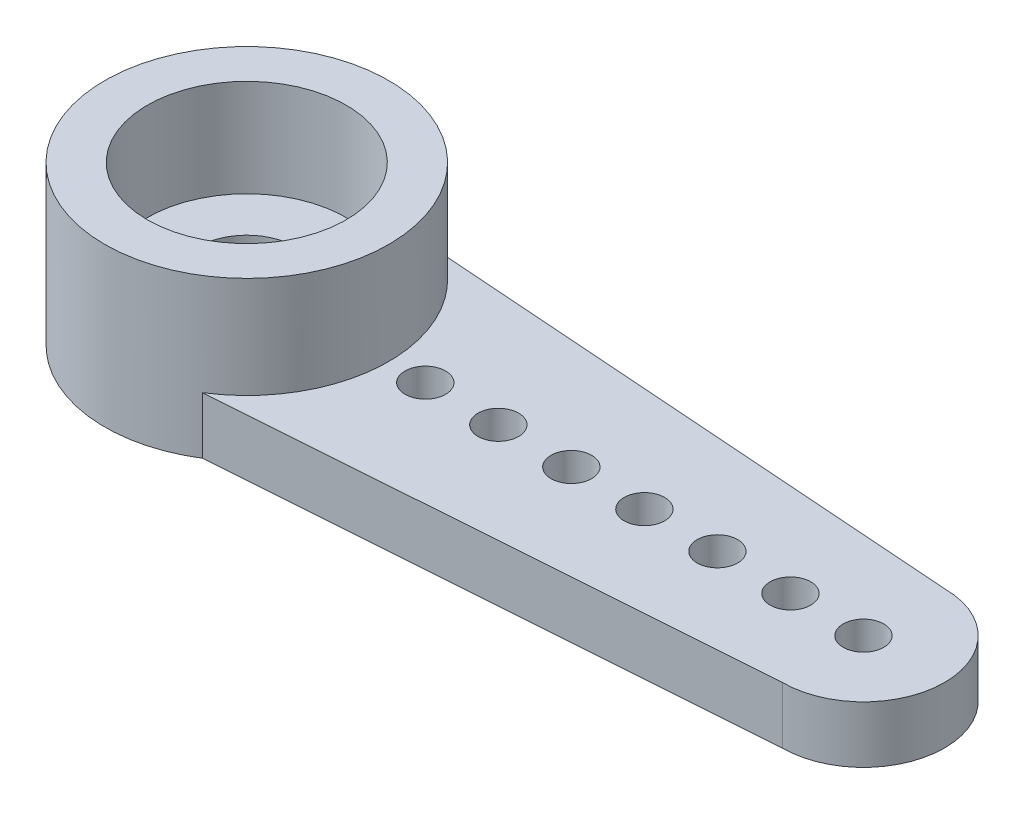
from build123d import *

# Parameters (mm, degrees)
SKETCH1_R           = 0.5
BOSS_EXTRUDE1_DEPTH = 1.4
SKETCH2_R           = 2.35
CUT_EXTRUDE1_DEPTH  = 1
SKETCH3_R           = 3.5
SKETCH3_R_2         = 2.45
BOSS_EXTRUDE2_DEPTH = 2.5
SKETCH4_R           = 1.2
CUT_EXTRUDE2_DEPTH  = 2.4
SKETCH5_R           = 2.45
SKETCH5_R_2         = 1.2
BOSS_EXTRUDE3_DEPTH = 0.1
SKETCH6_W           = 35.735260114
SKETCH6_H           = 17.672039004
CUT_EXTRUDE4_DEPTH  = 4.9
CUT_EXTRUDE5_DEPTH  = 4.9


with BuildPart() as part:
    # Sketch1 → Boss-Extrude1 (new body)
    with BuildSketch(Plane(origin=(0, 0, 0), x_dir=(1, 0, 0), z_dir=(0, 1, 0))):
        with BuildLine():
            Line((-15.2, 2), (-2, 2.95))
            Line((-2, 2.95), (-2, 6.35))
            ThreePointArc((-2, 6.35), (0, 8.35), (2, 6.35))
            Line((2, 6.35), (2, 3.5))
            Line((2, 3.5), (15.2, 2))
            ThreePointArc((15.2, 2), (17.2, 0), (15.2, -2))
            Line((15.2, -2), (2, -3.5))
            Line((2, -3.5), (2, -6.35))
            ThreePointArc((2, -6.35), (0, -8.35), (-2, -6.35))
            Line((-2, -6.35), (-2, -2.95))
            Line((-2, -2.95), (-15.2, -2))
            ThreePointArc((-15.2, -2), (-17.2, 0), (-15.2, 2))
        make_face()
        with Locations((0, 6.35)):
            Circle(SKETCH1_R, mode=Mode.SUBTRACT)
        with Locations((0, 4.55)):
            Circle(SKETCH1_R, mode=Mode.SUBTRACT)
        with Locations((0, -4.55)):
            Circle(SKETCH1_R, mode=Mode.SUBTRACT)
        with Locations((0, -6.35)):
            Circle(SKETCH1_R, mode=Mode.SUBTRACT)
        with Locations((-15.2, 0)):
            Circle(SKETCH1_R, mode=Mode.SUBTRACT)
        with Locations((15.2, 0)):
            Circle(SKETCH1_R, mode=Mode.SUBTRACT)
        with Locations((-13.4, 0)):
            Circle(SKETCH1_R, mode=Mode.SUBTRACT)
        with Locations((-11.6, 0)):
            Circle(SKETCH1_R, mode=Mode.SUBTRACT)
        with Locations((-9.8, 0)):
            Circle(SKETCH1_R, mode=Mode.SUBTRACT)
        with Locations((-8, 0)):
            Circle(SKETCH1_R, mode=Mode.SUBTRACT)
        with Locations((-6.2, 0)):
            Circle(SKETCH1_R, mode=Mode.SUBTRACT)
        with Locations((-4.4, 0)):
            Circle(SKETCH1_R, mode=Mode.SUBTRACT)
        with Locations((13.4, 0)):
            Circle(SKETCH1_R, mode=Mode.SUBTRACT)
        with Locations((11.6, 0)):
            Circle(SKETCH1_R, mode=Mode.SUBTRACT)
        with Locations((9.8, 0)):
            Circle(SKETCH1_R, mode=Mode.SUBTRACT)
        with Locations((8, 0)):
            Circle(SKETCH1_R, mode=Mode.SUBTRACT)
        with Locations((6.2, 0)):
            Circle(SKETCH1_R, mode=Mode.SUBTRACT)
        with Locations((4.4, 0)):
            Circle(SKETCH1_R, mode=Mode.SUBTRACT)
    extrude(amount=BOSS_EXTRUDE1_DEPTH)

    # Sketch2 → Cut-Extrude1 (cut)
    with BuildSketch(Plane.XZ):
        Circle(SKETCH2_R)
    extrude(amount=-CUT_EXTRUDE1_DEPTH, mode=Mode.SUBTRACT)

    # Sketch3 → Boss-Extrude2 (add)
    with BuildSketch(Plane(origin=(0, 1.4, 0), x_dir=(1, 0, 0), z_dir=(0, 1, 0))):
        Circle(SKETCH3_R)
        Circle(SKETCH3_R_2, mode=Mode.SUBTRACT)
    extrude(amount=BOSS_EXTRUDE2_DEPTH)

    # Sketch4 → Cut-Extrude2 (cut, through all)
    with BuildSketch(Plane(origin=(0, 1.4, 0), x_dir=(1, 0, 0), z_dir=(0, 1, 0))):
        Circle(SKETCH4_R)
    extrude(amount=-CUT_EXTRUDE2_DEPTH, mode=Mode.SUBTRACT)

    # Sketch5 → Boss-Extrude3 (add)
    with BuildSketch(Plane(origin=(0, 1.4, 0), x_dir=(1, 0, 0), z_dir=(0, 1, 0))):
        Circle(SKETCH5_R)
        Circle(SKETCH5_R_2, mode=Mode.SUBTRACT)
    extrude(amount=BOSS_EXTRUDE3_DEPTH)

    # Sketch6 → Cut-Extrude4 (cut, through all)
    with BuildSketch(Plane.XZ):
        Rectangle(SKETCH6_W, SKETCH6_H)
        with BuildLine():
            Line((-1.868584713, -2.959457918), (-15.2, -2))
            ThreePointArc((-15.2, -2), (-17.2, 0), (-15.2, 2))
            Line((-15.2, 2), (-1.868584713, 2.959457918))
            ThreePointArc((-1.868584713, 2.959457918), (0, 3.5), (1.868584713, 2.959457918))
            Line((1.868584713, 2.959457918), (15.2, 2))
            ThreePointArc((15.2, 2), (17.2, 0), (15.2, -2))
            Line((15.2, -2), (1.868584713, -2.959457918))
            ThreePointArc((1.868584713, -2.959457918), (0, -3.5), (-1.868584713, -2.959457918))
        make_face(mode=Mode.SUBTRACT)
    extrude(amount=-CUT_EXTRUDE4_DEPTH, mode=Mode.SUBTRACT)

    # Sketch7 → Cut-Extrude5 (cut, through all)
    with BuildSketch(Plane.XZ):
        with BuildLine():
            Line((0, 3.5), (-17.731768104, 3.5))
            Line((-17.731768104, 3.5), (-17.731768104, -3.5))
            Line((-17.731768104, -3.5), (0, -3.5))
            ThreePointArc((0, -3.5), (-3.5, 0), (0, 3.5))
        make_face()
    extrude(amount=-CUT_EXTRUDE5_DEPTH, mode=Mode.SUBTRACT)


solid = part.part
